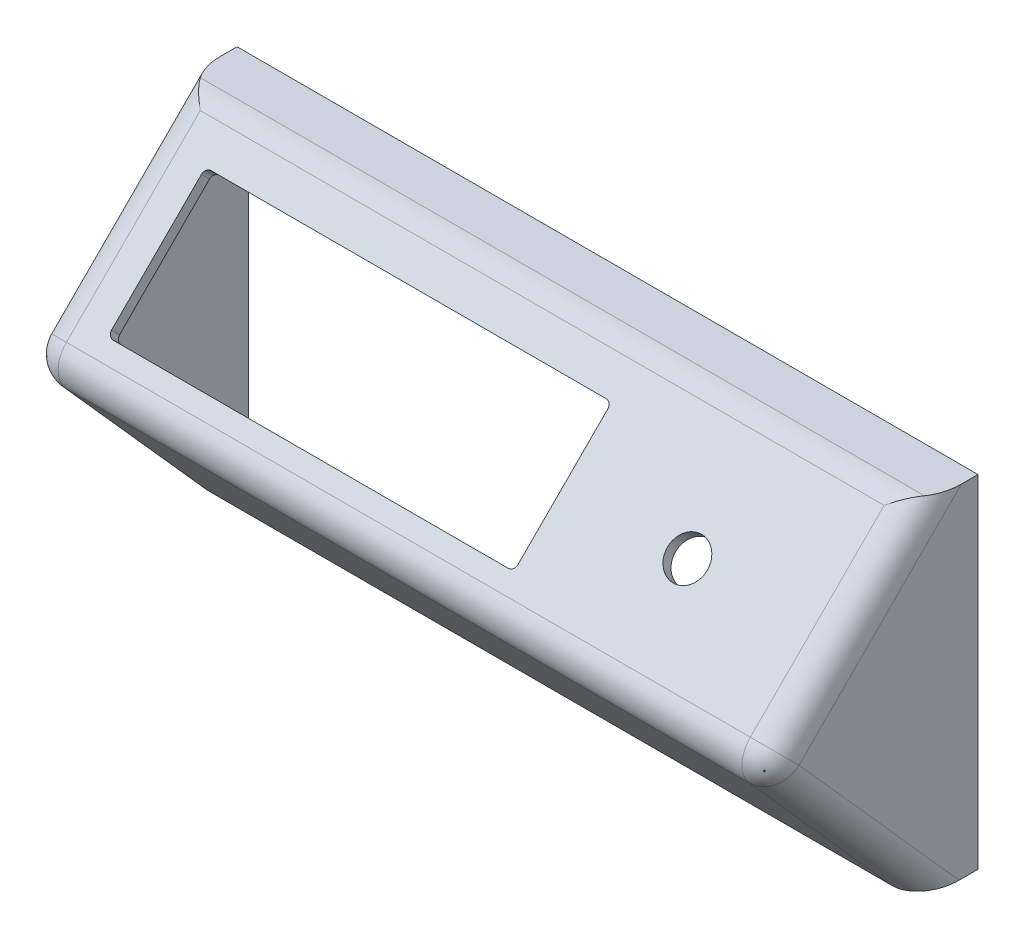
from build123d import *

# Parameters (mm, degrees)
BOSS_EXTRUDE1_DEPTH = 65
SHELL1_T            = -2
CUT_EXTRUDE1_DEPTH  = 100
FILLET1_R           = 5
SKETCH3_R           = 3.5
CUT_EXTRUDE2_DEPTH  = 100


with BuildPart() as part:
    # Sketch1 → Boss-Extrude1 (new body, symmetric)
    with BuildSketch(Plane(origin=(0, 0, 0), x_dir=(0, 0, -1), z_dir=(1, 0, 0))):
        Polygon((0, 60), (-28.284271247, 31.715728753), (0, 0), (10, 0), (10, 60), align=None)
    extrude(amount=BOSS_EXTRUDE1_DEPTH, both=True)

    # Shell1
    shell1_openings = [part.faces().sort_by_distance(p)[0] for p in [
        (0, 30, -10),
    ]]
    offset(amount=SHELL1_T, openings=shell1_openings, kind=Kind.INTERSECTION)

    # Sketch2 → Cut-Extrude1 (cut)
    with BuildSketch(Plane(origin=(0, 30, 30), x_dir=(1, 0, 0), z_dir=(0, 0.707106781, 0.707106781))):
        with BuildLine():
            Line((15.3, 10.276406871), (-54, 10.276406871))
            ThreePointArc((-54, 10.276406871), (-54.707106781, 10.56930009), (-55, 11.276406871))
            Line((-55, 11.276406871), (-55, 33.576406871))
            ThreePointArc((-55, 33.576406871), (-54.707106781, 34.283513652), (-54, 34.576406871))
            Line((-54, 34.576406871), (15.3, 34.576406871))
            ThreePointArc((15.3, 34.576406871), (16.007106781, 34.283513652), (16.3, 33.576406871))
            Line((16.3, 33.576406871), (16.3, 11.276406871))
            ThreePointArc((16.3, 11.276406871), (16.007106781, 10.56930009), (15.3, 10.276406871))
        make_face()
    extrude(amount=-CUT_EXTRUDE1_DEPTH, mode=Mode.SUBTRACT)

    # Fillet1
    fillet1_edges = [part.edges().sort_by_distance(p)[0] for p in [
        (65, 45.857864376, 14.142135624),
        (65, 15.857864376, 14.142135624),
        (-65, 15.857864376, 14.142135624),
        (-65, 45.857864376, 14.142135624),
        (0, 31.715728753, 28.284271247),
        (0, 60, 0),
    ]]
    fillet(fillet1_edges, radius=FILLET1_R)

    # Sketch3 → Cut-Extrude2 (cut)
    with BuildSketch(Plane(origin=(0, 30, 30), x_dir=(1, 0, 0), z_dir=(0, 0.707106781, 0.707106781))):
        with Locations((38.15, 22.426406871)):
            Circle(SKETCH3_R)
    extrude(amount=-CUT_EXTRUDE2_DEPTH, mode=Mode.SUBTRACT)


solid = part.part
